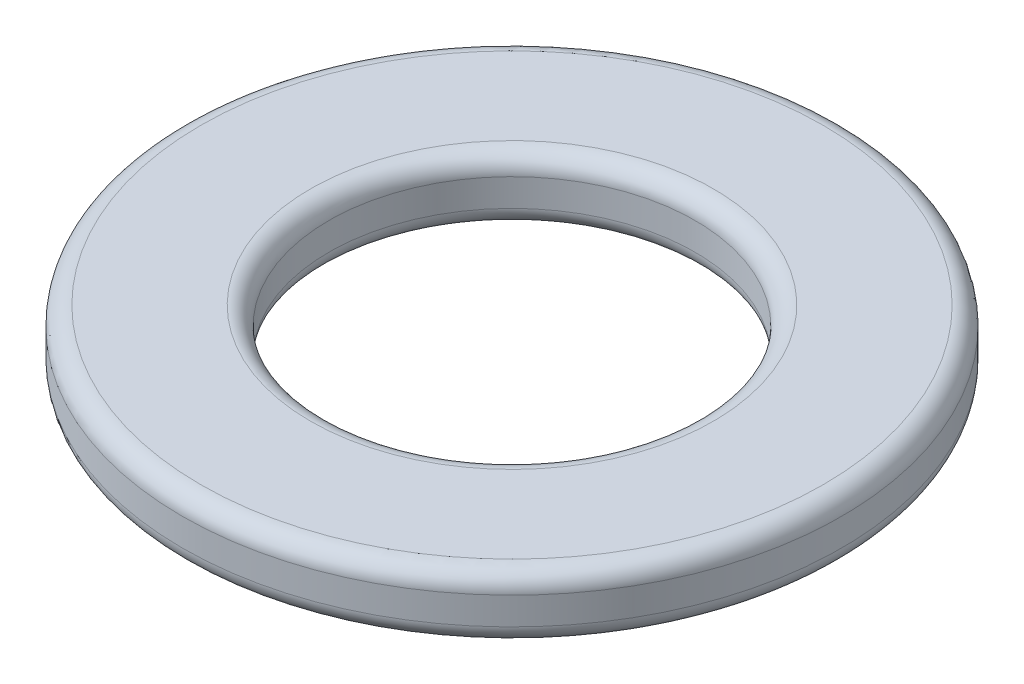
from build123d import *

# Parameters (mm, degrees)
SKETCH1_R           = 9
SKETCH1_R_2         = 5
BOSS_EXTRUDE1_DEPTH = 1.75
FILLET1_R           = 0.5


with BuildPart() as part:
    # Sketch1 → Boss-Extrude1 (new body)
    with BuildSketch(Plane(origin=(0, 0, 0), x_dir=(1, 0, 0), z_dir=(0, 1, 0))):
        Circle(SKETCH1_R)
        Circle(SKETCH1_R_2, mode=Mode.SUBTRACT)
    extrude(amount=BOSS_EXTRUDE1_DEPTH)

    # Fillet1
    fillet1_edges = [part.edges().sort_by_distance(p)[0] for p in [
        (-9, 0, 0),
        (-9, 1.75, 0),
        (-5, 0, 0),
        (-5, 1.75, 0),
    ]]
    fillet(fillet1_edges, radius=FILLET1_R)


solid = part.part
